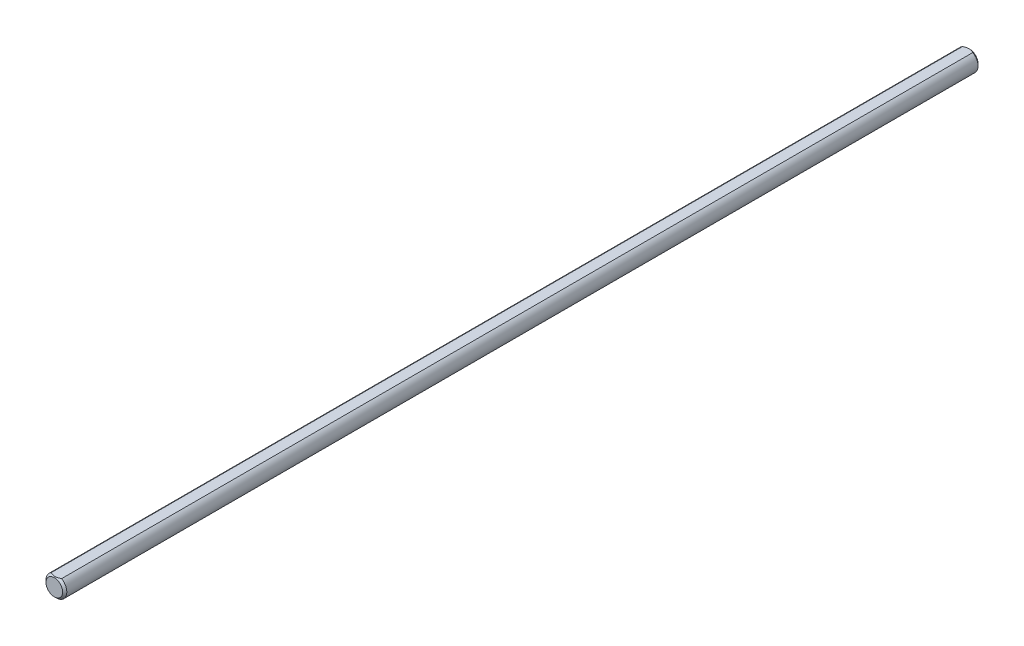
from build123d import *

# Parameters (mm, degrees)
SKETCH1_R           = 3.175
EXTRUDE1_DEPTH      = 139.7
CHAMFER1_SIZE       = 0.635
EXTRUDE7_DEPTH      = 140.7
EXTRUDE7_DEPTH_BACK = 140.7


with BuildPart() as part:
    # Sketch1 → Extrude1 (new body, symmetric)
    with BuildSketch(Plane.XY):
        Circle(SKETCH1_R)
    extrude(amount=EXTRUDE1_DEPTH, both=True)

    # Chamfer1
    chamfer1_edges = [part.edges().sort_by_distance(p)[0] for p in [
        (-3.175, 0, -139.7),
        (-3.175, 0, 139.7),
    ]]
    chamfer(chamfer1_edges, length=CHAMFER1_SIZE)

    # Sketch13 → Extrude7 (cut, two sides)
    with BuildSketch(Plane.XY) as extrude7_sk:
        with BuildLine():
            Line((-1.5875, 2.749630657), (1.5875, 2.749630657))
            ThreePointArc((1.5875, 2.749630657), (0, 3.175), (-1.5875, 2.749630657))
        make_face()
    extrude(amount=EXTRUDE7_DEPTH, mode=Mode.SUBTRACT)
    extrude(extrude7_sk.sketch, amount=-EXTRUDE7_DEPTH_BACK, mode=Mode.SUBTRACT)


solid = part.part
